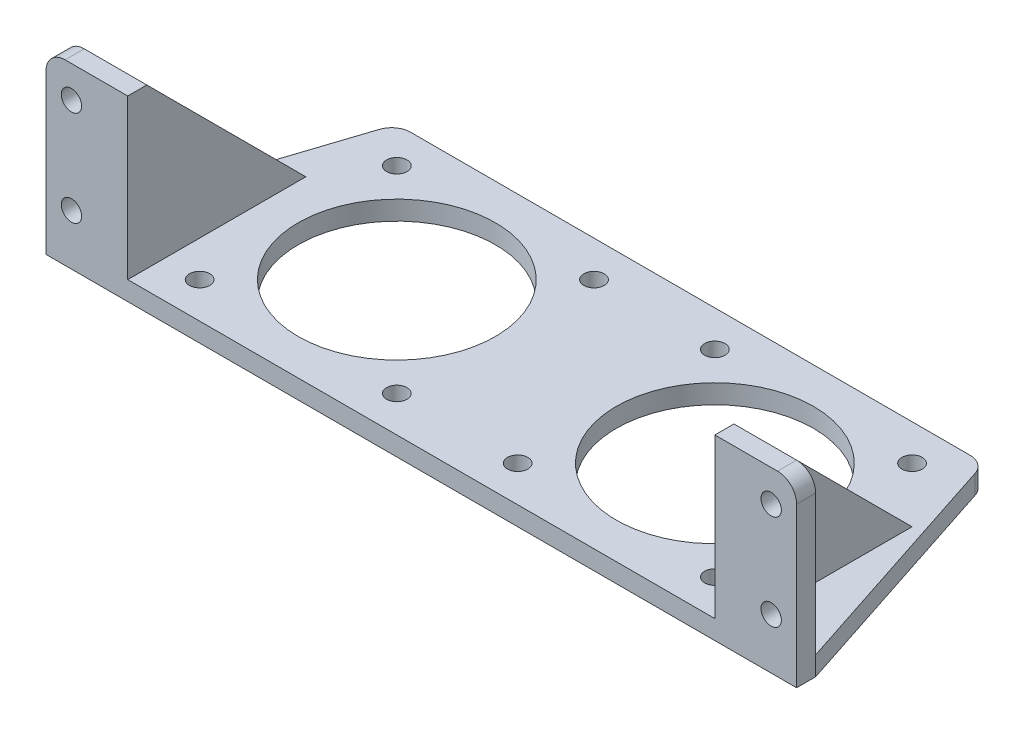
from build123d import *

# Parameters (mm, degrees)
SKETCH1_R                = 1.6
SKETCH1_R_2              = 15.5
BOSS_EXTRUDE1_DEPTH      = 3
SKETCH2_W                = 12.85
SKETCH2_H                = 3
BOSS_EXTRUDE2_DEPTH      = 25
SKETCH3_R                = 1.6
CUT_EXTRUDE1_DEPTH       = 4
BOSS_EXTRUDE3_DEPTH      = 3
CHAMFER1_SIZE            = 2
FILLET1_R                = 3
FILLET2_R                = 3
CHAMFER1_OF_MIRROR1_SIZE = 2
FILLET1_OF_MIRROR1_R     = 3


with BuildPart() as part:
    # Sketch1 → Boss-Extrude1 (new body)
    with BuildSketch(Plane(origin=(0, 0, 0), x_dir=(1, 0, 0), z_dir=(0, 1, 0))):
        Polygon((46.15, 13.849265428), (-46.15, 13.849265428), (-59, -25.450734572), (-59, -28.450734572), (59, -28.450734572), (59, -25.450734572), align=None)
        with Locations((-40.5, 8.199265428)):
            Circle(SKETCH1_R, mode=Mode.SUBTRACT)
        with Locations((-9.5, 8.199265428)):
            Circle(SKETCH1_R, mode=Mode.SUBTRACT)
        with Locations((-40.5, -22.800734572)):
            Circle(SKETCH1_R, mode=Mode.SUBTRACT)
        with Locations((-9.5, -22.800734572)):
            Circle(SKETCH1_R, mode=Mode.SUBTRACT)
        with Locations((-25, -7.300734572)):
            Circle(SKETCH1_R_2, mode=Mode.SUBTRACT)
        with Locations((40.5, -22.800734572)):
            Circle(SKETCH1_R, mode=Mode.SUBTRACT)
        with Locations((9.5, -22.800734572)):
            Circle(SKETCH1_R, mode=Mode.SUBTRACT)
        with Locations((9.5, 8.199265428)):
            Circle(SKETCH1_R, mode=Mode.SUBTRACT)
        with Locations((40.5, 8.199265428)):
            Circle(SKETCH1_R, mode=Mode.SUBTRACT)
        with Locations((25, -7.300734572)):
            Circle(SKETCH1_R_2, mode=Mode.SUBTRACT)
    extrude(amount=BOSS_EXTRUDE1_DEPTH)

    # Sketch2 → Boss-Extrude2 (add)
    with BuildSketch(Plane(origin=(0, 3, 0), x_dir=(1, 0, 0), z_dir=(0, 1, 0))):
        with Locations((-52.575, -26.950734572)):
            Rectangle(SKETCH2_W, SKETCH2_H)
    boss_extrude2 = extrude(amount=BOSS_EXTRUDE2_DEPTH)

    # Sketch3 → Cut-Extrude1 (cut, through all)
    with BuildSketch(Plane(origin=(0, 0, 25.450734572), x_dir=(-1, 0, 0), z_dir=(0, 0, -1))):
        with Locations((55, 8)):
            Circle(SKETCH3_R)
        with Locations((55, 23)):
            Circle(SKETCH3_R)
    cut_extrude1 = extrude(amount=-CUT_EXTRUDE1_DEPTH, mode=Mode.SUBTRACT)

    # Sketch4 → Boss-Extrude3 (add)
    with BuildSketch(Plane(origin=(-46.15, 0, 0), x_dir=(0, 0, -1), z_dir=(1, 0, 0))):
        Polygon((-25.450734572, 28), (-0.450734572, 3), (-25.450734572, 3), align=None)
    boss_extrude3 = extrude(amount=-BOSS_EXTRUDE3_DEPTH)

    # Chamfer1
    chamfer1_edges = [part.edges().sort_by_distance(p)[0] for p in [
        (-49.15, 15.5, 25.450734572),
    ]]
    chamfer(chamfer1_edges, length=CHAMFER1_SIZE)

    # Fillet1
    fillet1_edges = [part.edges().sort_by_distance(p)[0] for p in [
        (-59, 28, 26.950734572),
    ]]
    fillet(fillet1_edges, radius=FILLET1_R)

    # Fillet2
    fillet2_edges = [part.edges().sort_by_distance(p)[0] for p in [
        (-46.15, 1.5, -13.849265428),
        (46.15, 1.5, -13.849265428),
    ]]
    fillet(fillet2_edges, radius=FILLET2_R)

    # Mirror1: Boss-Extrude2, Cut-Extrude1, Boss-Extrude3 across plane
    add(boss_extrude2.mirror(Plane(origin=(0, 0, 0), x_dir=(0, 0, 1), z_dir=(1, 0, 0))))
    add(cut_extrude1.mirror(Plane(origin=(0, 0, 0), x_dir=(0, 0, 1), z_dir=(1, 0, 0))), mode=Mode.SUBTRACT)
    add(boss_extrude3.mirror(Plane(origin=(0, 0, 0), x_dir=(0, 0, 1), z_dir=(1, 0, 0))))

    # Chamfer1 of Mirror1
    chamfer1_of_mirror1_edges = [part.edges().sort_by_distance(p)[0] for p in [
        (49.15, 15.5, 25.450734572),
    ]]
    chamfer(chamfer1_of_mirror1_edges, length=CHAMFER1_OF_MIRROR1_SIZE)

    # Fillet1 of Mirror1
    fillet1_of_mirror1_edges = [part.edges().sort_by_distance(p)[0] for p in [
        (59, 28, 26.950734572),
    ]]
    fillet(fillet1_of_mirror1_edges, radius=FILLET1_OF_MIRROR1_R)


solid = part.part
